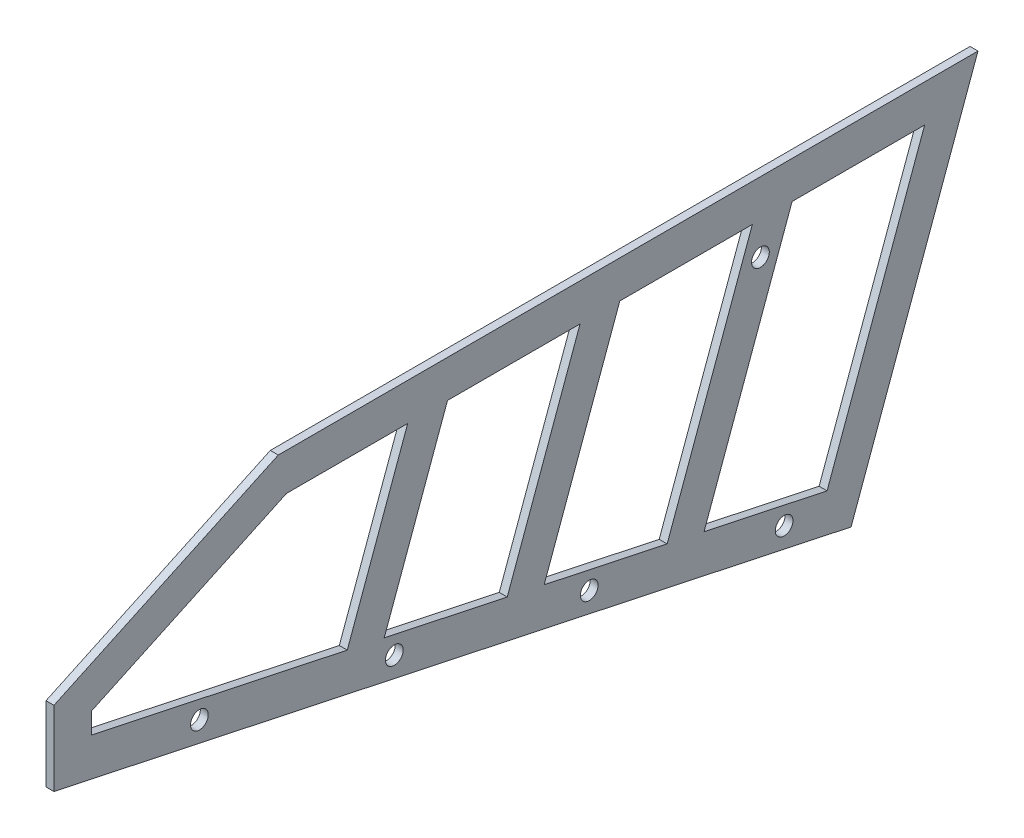
from build123d import *

# Parameters (mm, degrees)
EXTRUDE1_DEPTH     = 0.635
SKETCH2_R          = 1.5875
EXTRUDE2_DEPTH     = 1.635
SKETCH3_R          = 1.1303
EXTRUDE3_DEPTH     = 1.016
EXTRUDE4_DEPTH     = 0.635
SKETCH5_R          = 1.1303
CUT_EXTRUDE1_DEPTH = 2.016


with BuildPart() as part:
    # Sketch1 → Extrude1 (new body)
    with BuildSketch(Plane(origin=(0, 0, 0), x_dir=(0, 0, -1), z_dir=(1, 0, 0))):
        Polygon((16.178476913, 44.45), (0, 0), (-101.6, 21.595746666), (-101.6, 31.120746666), (-73.015323979, 44.45), align=None)
    extrude(amount=EXTRUDE1_DEPTH)

    # Sketch2 → Extrude2 (cut, through all)
    with BuildSketch(Plane.ZY):
        with Locations((8.531149291, 4.410096871)):
            Circle(SKETCH2_R)
        with Locations((33.37609835, 9.691053818)):
            Circle(SKETCH2_R)
        with Locations((58.221047409, 14.972010765)):
            Circle(SKETCH2_R)
        with Locations((83.065996467, 20.252967712)):
            Circle(SKETCH2_R)
    extrude(amount=-EXTRUDE2_DEPTH, mode=Mode.SUBTRACT)

    # Sketch4 → Extrude4 (cut)
    with BuildSketch(Plane.ZY):
        Polygon((73.015323979, 44.45), (-16.178476913, 44.45), (0, 0), (101.6, 21.595746666), (101.6, 31.120746666), align=None)
    extrude(amount=-EXTRUDE4_DEPTH, mode=Mode.SUBTRACT)


with BuildPart() as body_2:
    # Sketch3 → Extrude3 (new body)
    with BuildSketch(Plane.ZY.offset(-0.635)):
        Polygon((-16.178476913, 44.45), (0, 0), (101.6, 21.595746666), (101.6, 31.120746666), (73.015323979, 44.45), align=None)
        with Locations((8.531149291, 4.410096871)):
            Circle(SKETCH3_R, mode=Mode.SUBTRACT)
        with Locations((33.37609835, 9.691053818)):
            Circle(SKETCH3_R, mode=Mode.SUBTRACT)
        with Locations((58.221047409, 14.972010765)):
            Circle(SKETCH3_R, mode=Mode.SUBTRACT)
        with Locations((83.065996467, 20.252967712)):
            Circle(SKETCH3_R, mode=Mode.SUBTRACT)
        Polygon((7.516900107, 39.6875), (-9.376922031, 39.6875), (3.059330207, 5.519177793), (18.74002683, 8.852212752), align=None, mode=Mode.SUBTRACT)
        Polygon((23.444235817, 9.852123239), (39.124932441, 13.185158198), (29.478868887, 39.6875), (12.585046748, 39.6875), align=None, mode=Mode.SUBTRACT)
        Polygon((34.547015528, 39.6875), (43.829141428, 14.185068686), (59.509838051, 17.518103645), (51.440837666, 39.6875), align=None, mode=Mode.SUBTRACT)
        Polygon((56.508984307, 39.6875), (64.214047038, 18.518014132), (96.8375, 25.452343124), (96.8375, 28.086699549), (71.959503148, 39.6875), align=None, mode=Mode.SUBTRACT)
    extrude(amount=-EXTRUDE3_DEPTH)

    # Sketch5 → Cut-Extrude1 (cut, through all)
    with BuildSketch(Plane(origin=(1.651, 0, 0), x_dir=(0, 0, -1), z_dir=(1, 0, 0))):
        with Locations((-11.55326057, 35.56)):
            Circle(SKETCH5_R)
    extrude(amount=-CUT_EXTRUDE1_DEPTH, mode=Mode.SUBTRACT)


solid = body_2.part
